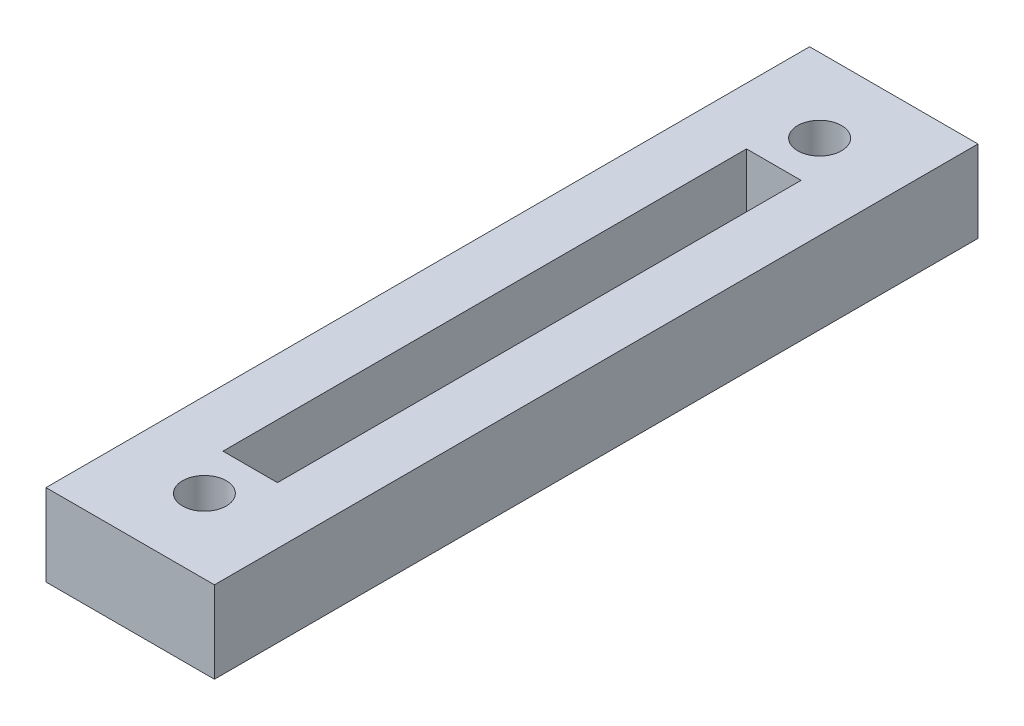
from build123d import *

# Parameters (mm, degrees)
SKETCH1_W                  = 19.6088
SKETCH1_H                  = 88.9
SKETCH1_R                  = 2.54
BOSS_EXTRUDE1_DEPTH        = 9.525
SKETCH2_W                  = 6.35
SKETCH2_H                  = 60.96
CUT_EXTRUDE1_DEPTH         = 6.477
F_10_32_TAPPED_HOLE4_D     = 5.1054
F_10_32_TAPPED_HOLE4_DEPTH = 16.51
F_10_32_TAPPED_HOLE4_TIP   = 1.533816902


with BuildPart() as part:
    # Sketch1 → Boss-Extrude1 (new body)
    with BuildSketch(Plane(origin=(0, 0, 0), x_dir=(1, 0, 0), z_dir=(0, 1, 0))):
        with Locations((9.8044, 44.45)):
            Rectangle(SKETCH1_W, SKETCH1_H)
        with Locations((9.8044, 80.264)):
            Circle(SKETCH1_R, mode=Mode.SUBTRACT)
        with Locations((9.8044, 8.636)):
            Circle(SKETCH1_R, mode=Mode.SUBTRACT)
    extrude(amount=BOSS_EXTRUDE1_DEPTH)

    # Sketch2 → Cut-Extrude1 (cut)
    with BuildSketch(Plane(origin=(0, 9.525, 0), x_dir=(1, 0, 0), z_dir=(0, 1, 0))):
        with Locations((9.8044, 44.45)):
            Rectangle(SKETCH2_W, SKETCH2_H)
    extrude(amount=-CUT_EXTRUDE1_DEPTH, mode=Mode.SUBTRACT)

    # #10-32 Tapped Hole4
    with Locations(Plane(origin=(0, 9.525, 0), x_dir=(1, 0, 0), z_dir=(0, 1, 0))):
        with Locations((9.8044, 80.264), (9.8044, 8.636)):
            Hole(F_10_32_TAPPED_HOLE4_D / 2, depth=F_10_32_TAPPED_HOLE4_DEPTH)
            with Locations((0, 0, -(F_10_32_TAPPED_HOLE4_DEPTH + F_10_32_TAPPED_HOLE4_TIP / 2))):  # 118° drill point
                Cone(0, F_10_32_TAPPED_HOLE4_D / 2, F_10_32_TAPPED_HOLE4_TIP, mode=Mode.SUBTRACT)


solid = part.part
